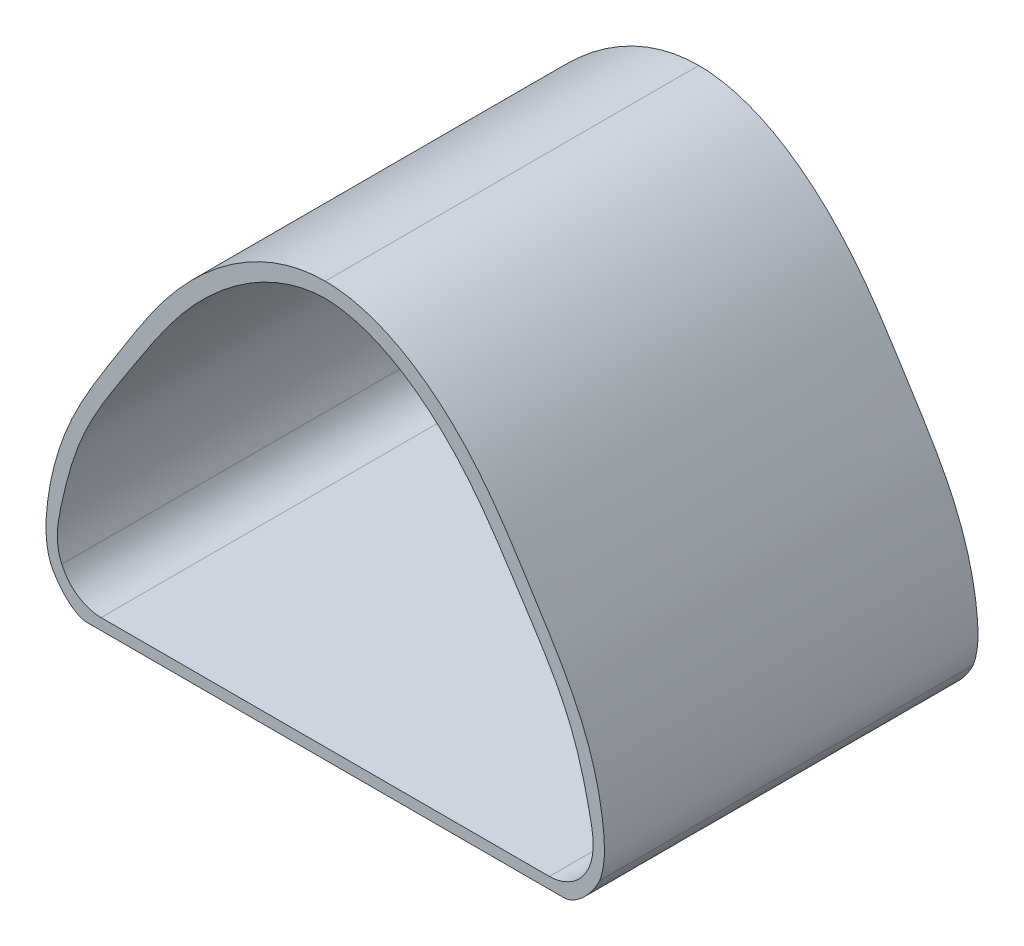
from build123d import *

# Parameters (mm, degrees)
EXTRUDE_1_DEPTH = 50


with BuildPart() as part:
    # 草图1 → 凸台-拉伸1 (new body)
    with BuildSketch(Plane.XY):
        with BuildLine():
            Line((-32, -21.5), (32, -21.5))
            add(Edge.make_bspline(
                [(36.733909542, -17.129303333), (36.442708458, -17.789293258), (35.093003072, -20.035409342), (32.859902831, -21.483095563), (32, -21.5)],
                knots=[0, 0, 0, 0, 0.489167663, 1, 1, 1, 1], degree=3))
            add(Edge.make_bspline(
                [(0, 34), (7.555913279, 34.011602268), (18.959944892, 25.933619789), (27.410768064, 12.158954921), (34.505617486, 1.231569585), (37.368528413, -8.742517367), (37.515489023, -15.116686236), (36.733909542, -17.129303333)],
                knots=[0, 0, 0, 0, 0.330857753, 0.539322829, 0.730827311, 0.902654757, 1, 1, 1, 1], degree=3))
            add(Edge.make_bspline(
                [(0, 34), (-7.555913279, 34.011602268), (-18.959944892, 25.933619789), (-27.410768064, 12.158954921), (-34.505617486, 1.231569585), (-37.368528413, -8.742517367), (-37.515489023, -15.116686236), (-36.733909542, -17.129303333)],
                knots=[0, 0, 0, 0, 0.330857753, 0.539322829, 0.730827311, 0.902654757, 1, 1, 1, 1], degree=3))
            add(Edge.make_bspline(
                [(-36.733909542, -17.129303333), (-36.442708458, -17.789293258), (-35.093003072, -20.035409342), (-32.859902831, -21.483095563), (-32, -21.5)],
                knots=[0, 0, 0, 0, 0.489167663, 1, 1, 1, 1], degree=3))
        make_face()
        with BuildLine():
            Line((-30, -20), (30, -20))
            add(Edge.make_bspline(
                [(35.258436844, -16.441279115), (34.996443421, -17.020908852), (33.690556146, -19.14256109), (31.185354686, -20.029316023), (30, -20)],
                knots=[0, 0, 0, 0, 0.359900696, 1, 1, 1, 1], degree=3))
            add(Edge.make_bspline(
                [(0, 32), (6.525531342, 31.903595671), (17.503513361, 24.330693276), (25.717632299, 11.137446439), (32.791173162, 0.606888673), (35.263590912, -8.864538837), (36.230061186, -14.212016256), (35.258436844, -16.441279115)],
                knots=[0, 0, 0, 0, 0.310761872, 0.543527622, 0.745406531, 0.898184222, 1, 1, 1, 1], degree=3))
            add(Edge.make_bspline(
                [(0, 32), (-6.525531342, 31.903595671), (-17.503513361, 24.330693276), (-25.717632299, 11.137446439), (-32.791173162, 0.606888673), (-35.263590912, -8.864538837), (-36.230061186, -14.212016256), (-35.258436844, -16.441279115)],
                knots=[0, 0, 0, 0, 0.310761872, 0.543527622, 0.745406531, 0.898184222, 1, 1, 1, 1], degree=3))
            add(Edge.make_bspline(
                [(-35.258436844, -16.441279115), (-34.996443421, -17.020908852), (-33.690556146, -19.14256109), (-31.185354686, -20.029316023), (-30, -20)],
                knots=[0, 0, 0, 0, 0.359900696, 1, 1, 1, 1], degree=3))
        make_face(mode=Mode.SUBTRACT)
    extrude(amount=EXTRUDE_1_DEPTH)


solid = part.part
